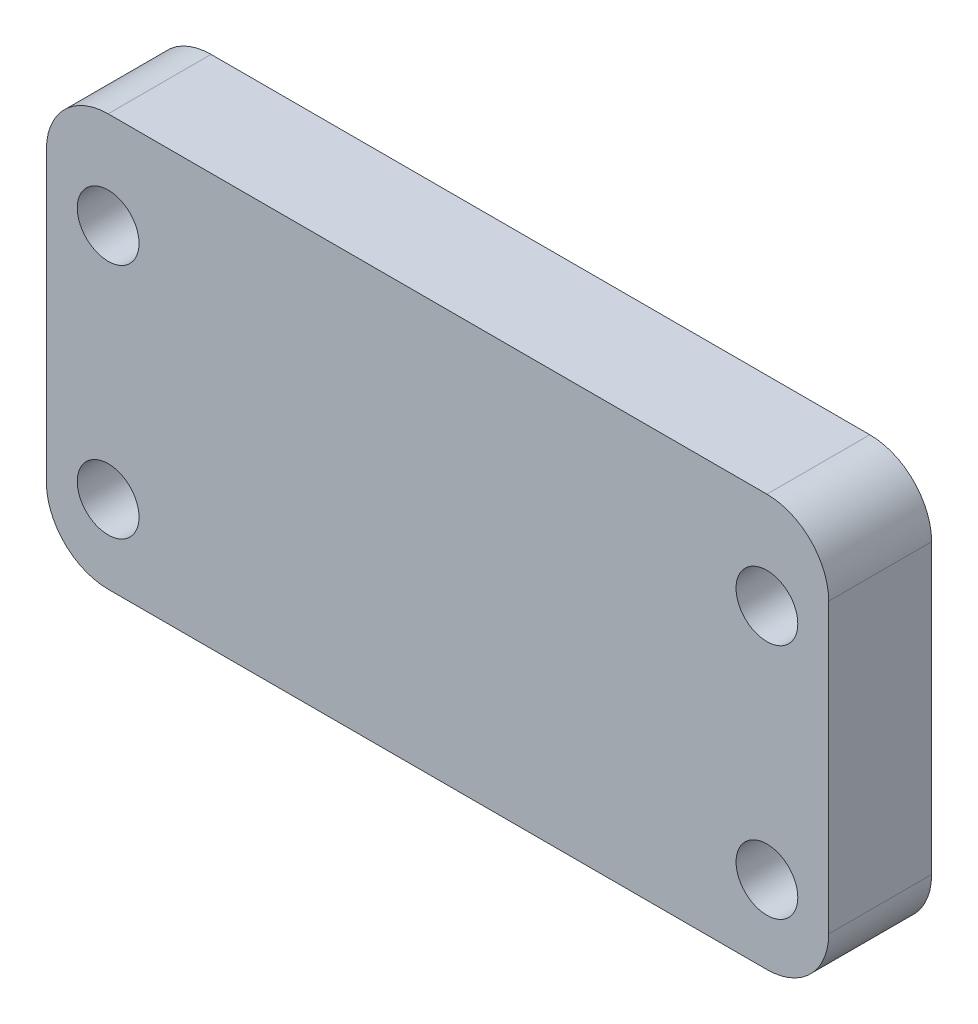
from build123d import *

# Parameters (mm, degrees)
SKETCH1_W           = 38
SKETCH1_H           = 20
SKETCH1_R           = 1.5
BOSS_EXTRUDE1_DEPTH = 5
FILLET1_R           = 3
FILLET2_R           = 3
FILLET3_R           = 3
FILLET4_R           = 3


with BuildPart() as part:
    # Sketch1 → Boss-Extrude1 (new body)
    with BuildSketch(Plane.XY):
        with Locations((4.889250814, 9.866449511)):
            Rectangle(SKETCH1_W, SKETCH1_H)
        with Locations((-11.110749186, 15.16286645)):
            Circle(SKETCH1_R, mode=Mode.SUBTRACT)
        with Locations((-11.110749186, 3.651465798)):
            Circle(SKETCH1_R, mode=Mode.SUBTRACT)
        with Locations((20.889250814, 15.16286645)):
            Circle(SKETCH1_R, mode=Mode.SUBTRACT)
        with Locations((20.889250814, 3.651465798)):
            Circle(SKETCH1_R, mode=Mode.SUBTRACT)
    extrude(amount=BOSS_EXTRUDE1_DEPTH)

    # Fillet1
    fillet1_edges = [part.edges().sort_by_distance(p)[0] for p in [
        (23.889250814, 19.866449511, 2.5),
    ]]
    fillet(fillet1_edges, radius=FILLET1_R)

    # Fillet2
    fillet2_edges = [part.edges().sort_by_distance(p)[0] for p in [
        (23.889250814, -0.133550489, 2.5),
    ]]
    fillet(fillet2_edges, radius=FILLET2_R)

    # Fillet3
    fillet3_edges = [part.edges().sort_by_distance(p)[0] for p in [
        (-14.110749186, -0.133550489, 2.5),
    ]]
    fillet(fillet3_edges, radius=FILLET3_R)

    # Fillet4
    fillet4_edges = [part.edges().sort_by_distance(p)[0] for p in [
        (-14.110749186, 19.866449511, 2.5),
    ]]
    fillet(fillet4_edges, radius=FILLET4_R)


solid = part.part
